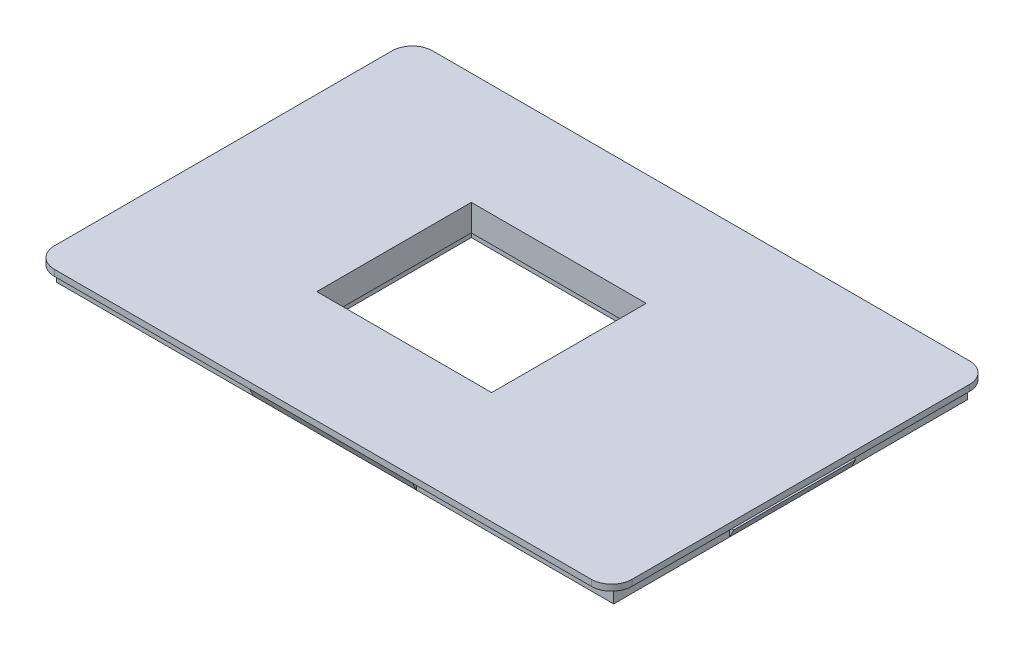
from build123d import *

# Parameters (mm, degrees)
SKETCH1_W                = 142
SKETCH1_H                = 93
BOSS_EXTRUDE1_DEPTH      = 1.5
SKETCH3_W                = 137
SKETCH3_H                = 87
SKETCH3_W_2              = 135
SKETCH3_H_2              = 85
EXTRUDE_THIN1_DEPTH      = 4
FILLET1_R                = 5
BOSS_EXTRUDE2_DEPTH      = 20
BOSS_EXTRUDE2_DEPTH_BACK = 20
BOSS_EXTRUDE3_DEPTH      = 15
BOSS_EXTRUDE3_DEPTH_BACK = 15
SKETCH6_W                = 58
SKETCH6_H                = 38
CUT_EXTRUDE2_DEPTH       = 10
SKETCH6_5_W              = 60
SKETCH6_5_H              = 40
SKETCH6_5_W_2            = 58
SKETCH6_5_H_2            = 38
BOSS_EXTRUDE4_DEPTH      = 5
SKETCH6_6_W              = 64
SKETCH6_6_H              = 44
SKETCH6_6_W_2            = 60
SKETCH6_6_H_2            = 40
BOSS_EXTRUDE5_DEPTH      = 7
SKETCH7_W                = 15
SKETCH7_H                = 38
BOSS_EXTRUDE6_DEPTH      = 1.5
BOSS_EXTRUDE7_REACH      = 67.5
SKETCH8_W                = 2.25753837
SKETCH8_H                = 5


with BuildPart() as part:
    # Sketch1 → Boss-Extrude1 (new body)
    with BuildSketch(Plane(origin=(0, 0, 0), x_dir=(1, 0, 0), z_dir=(0, 1, 0))):
        with Locations((68.5, 43.5)):
            Rectangle(SKETCH1_W, SKETCH1_H)
    extrude(amount=BOSS_EXTRUDE1_DEPTH)

    # Fillet1
    fillet1_edges = [part.edges().sort_by_distance(p)[0] for p in [
        (-2.5, 0.75, -90),
        (139.5, 0.75, -90),
        (139.5, 0.75, 3),
        (-2.5, 0.75, 3),
    ]]
    fillet(fillet1_edges, radius=FILLET1_R)

    # Sketch6 → Cut-Extrude2 (cut)
    with BuildSketch(Plane(origin=(0, 0, 0), x_dir=(-1, 0, 0), z_dir=(0, -1, 0))):
        with Locations((-68.5, 43.5)):
            Rectangle(SKETCH6_W, SKETCH6_H)
    extrude(amount=-CUT_EXTRUDE2_DEPTH, mode=Mode.SUBTRACT)


with BuildPart() as body_2:
    # Sketch3 → Extrude-Thin1 (new body)
    with BuildSketch(Plane(origin=(0, 0, 0), x_dir=(1, 0, 0), z_dir=(0, 1, 0))):
        with Locations((68.5, 43.5)):
            Rectangle(SKETCH3_W, SKETCH3_H)
        with Locations((68.5, 43.5)):
            Rectangle(SKETCH3_W_2, SKETCH3_H_2, mode=Mode.SUBTRACT)
    extrude(amount=-EXTRUDE_THIN1_DEPTH)

    # Sketch4 → Boss-Extrude2 (add, two sides)
    with BuildSketch(Plane(origin=(68.5, 0, 0), x_dir=(0, 0, -1), z_dir=(1, 0, 0))) as boss_extrude2_sk:
        Polygon((87, -2), (87, -4), (88, -2), align=None)
        Polygon((-1, -2), (0, -2), (0, -4), align=None)
    extrude(amount=BOSS_EXTRUDE2_DEPTH)
    extrude(boss_extrude2_sk.sketch, amount=-BOSS_EXTRUDE2_DEPTH_BACK)

    # Sketch5 → Boss-Extrude3 (add, two sides)
    with BuildSketch(Plane.XY.offset(-43.5)) as boss_extrude3_sk:
        Polygon((137, -2), (137, -4), (138, -2), align=None)
        Polygon((-1, -2), (0, -2), (0, -4), align=None)
    extrude(amount=BOSS_EXTRUDE3_DEPTH)
    extrude(boss_extrude3_sk.sketch, amount=-BOSS_EXTRUDE3_DEPTH_BACK)


    add(part.part)  # Boss-Extrude4 merges part
    # Sketch6_5 → Boss-Extrude4 (add)
    with BuildSketch(Plane(origin=(0, 0, 0), x_dir=(-1, 0, 0), z_dir=(0, -1, 0))):
        with Locations((-68.5, 43.5)):
            Rectangle(SKETCH6_5_W, SKETCH6_5_H)
        with Locations((-68.5, 43.5)):
            Rectangle(SKETCH6_5_W_2, SKETCH6_5_H_2, mode=Mode.SUBTRACT)
    extrude(amount=BOSS_EXTRUDE4_DEPTH)

    # Sketch6_6 → Boss-Extrude5 (add)
    with BuildSketch(Plane(origin=(0, 0, 0), x_dir=(-1, 0, 0), z_dir=(0, -1, 0))):
        with Locations((-68.5, 43.5)):
            Rectangle(SKETCH6_6_W, SKETCH6_6_H)
        with Locations((-68.5, 43.5)):
            Rectangle(SKETCH6_6_W_2, SKETCH6_6_H_2, mode=Mode.SUBTRACT)
    extrude(amount=BOSS_EXTRUDE5_DEPTH)

    # Sketch7 → Boss-Extrude6 (add)
    with BuildSketch(Plane(origin=(0, 1.5, 0), x_dir=(1, 0, 0), z_dir=(0, 1, 0))):
        with Locations((90, 43.5)):
            Rectangle(SKETCH7_W, SKETCH7_H)
    extrude(amount=-BOSS_EXTRUDE6_DEPTH)

    # Sketch8 → Boss-Extrude7 (add, up to next)
    with BuildSketch(Plane(origin=(0, 0, -24.5), x_dir=(-1, 0, 0), z_dir=(0, 0, -1)), mode=Mode.PRIVATE) as boss_extrude7_sk1:
        with Locations((-83.628769185, -2.5)):
            Rectangle(SKETCH8_W, SKETCH8_H)
    boss_extrude7_tool1 = extrude(boss_extrude7_sk1.sketch, amount=BOSS_EXTRUDE7_REACH, mode=Mode.PRIVATE) - body_2.part
    add(boss_extrude7_tool1.solids().sort_by_distance((83.628769, -2.5, -24.5))[0])


solid = body_2.part
